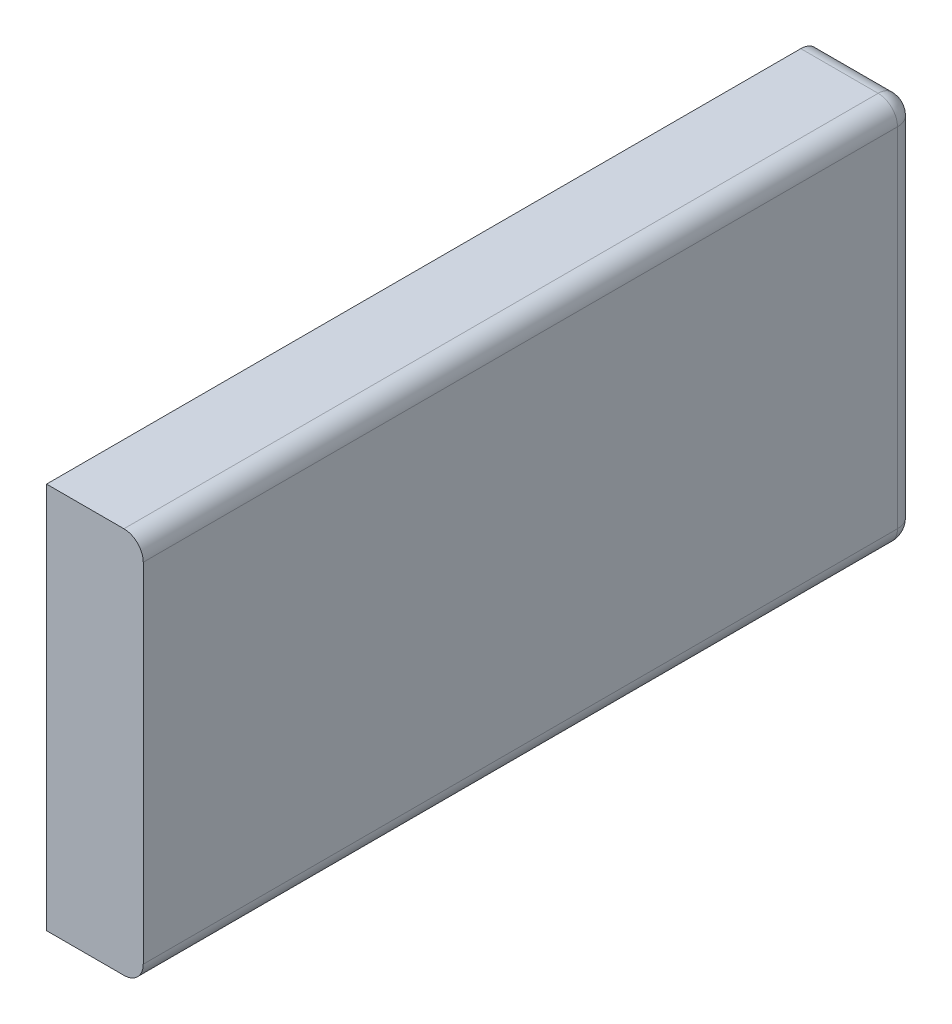
from build123d import *

# Parameters (mm, degrees)
SKETCH2_W           = 12.7
SKETCH2_H           = 101.6
BOSS_EXTRUDE3_DEPTH = 50.8
FILLET2_R           = 2.54


with BuildPart() as part:
    # Sketch2 → Boss-Extrude3 (new body)
    with BuildSketch(Plane(origin=(0, 0, 0), x_dir=(1, 0, 0), z_dir=(0, 1, 0))):
        with Locations((6.35, 50.8)):
            Rectangle(SKETCH2_W, SKETCH2_H)
    extrude(amount=BOSS_EXTRUDE3_DEPTH)

    # Fillet2
    fillet2_edges = [part.edges().sort_by_distance(p)[0] for p in [
        (6.35, 50.8, -101.6),
        (6.35, 0, -101.6),
        (12.7, 0, -50.8),
        (12.7, 25.4, -101.6),
        (12.7, 50.8, -50.8),
    ]]
    fillet(fillet2_edges, radius=FILLET2_R)


solid = part.part
